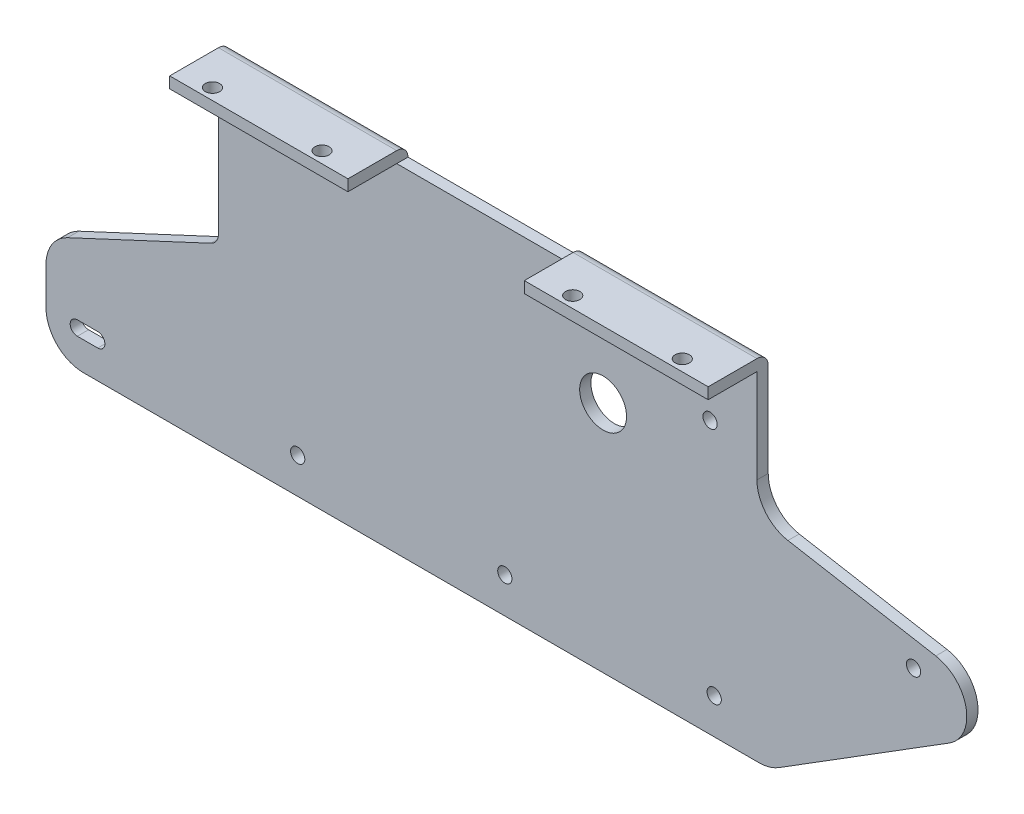
from build123d import *

# Parameters (mm, degrees)
BOSS_EXTRUDE1_DEPTH = 3
SKETCH2_R           = 1.9
SKETCH2_R_2         = 6.25
CUT_EXTRUDE1_DEPTH  = 4
BOSS_EXTRUDE3_DEPTH = 143.5
SKETCH6_W           = 47
SKETCH6_H           = 16
CUT_EXTRUDE4_DEPTH  = 3
SKETCH7_R           = 1.9
CUT_EXTRUDE5_DEPTH  = 94


with BuildPart() as part:
    # Sketch1 → Boss-Extrude1 (new body)
    with BuildSketch(Plane.XY):
        with BuildLine():
            Line((0, 0), (143.5, 0))
            Line((143.5, 0), (143.5, -25))
            ThreePointArc((143.5, -25), (145.839555569, -31.427876097), (151.763518223, -34.84807753))
            Line((151.763518223, -34.84807753), (191.155828344, -41.794004637))
            ThreePointArc((191.155828344, -41.794004637), (199.235618402, -49.733992213), (194.718539209, -60.122563128))
            Line((194.718539209, -60.122563128), (149.336384129, -88.480480962))
            ThreePointArc((149.336384129, -88.480480962), (146.793565045, -89.612616959), (144.037191487, -90))
            Line((144.037191487, -90), (-35.962808513, -90))
            ThreePointArc((-35.962808513, -90), (-43.033876325, -87.071067812), (-45.962808513, -80))
            Line((-45.962808513, -80), (-45.962808513, -70))
            ThreePointArc((-45.962808513, -70), (-44.396722971, -64.627003917), (-40.18899113, -60.93692213))
            Line((-40.18899113, -60.93692213), (-1.99069399, -43.124763645))
            ThreePointArc((-1.99069399, -43.124763645), (-0.539954223, -41.852499015), (0, -40))
            Line((0, -40), (0, 0))
        make_face()
    extrude(amount=BOSS_EXTRUDE1_DEPTH)

    # Sketch2 → Cut-Extrude1 (cut, through all)
    with BuildSketch(Plane.XY.offset(3)):
        with Locations((185.228339525, -47.568848131)):
            Circle(SKETCH2_R)
        with Locations((132.107823371, -80.5)):
            Circle(SKETCH2_R)
        with Locations((76.307823371, -80.5)):
            Circle(SKETCH2_R)
        with Locations((21.107823371, -80.5)):
            Circle(SKETCH2_R)
        with Locations((102.5, -27.75)):
            Circle(SKETCH2_R_2)
        with Locations((131.007823371, -17.5)):
            Circle(SKETCH2_R)
        with BuildLine():
            Line((-32.167176629, -82.4), (-37.617176629, -82.4))
            ThreePointArc((-37.617176629, -82.4), (-39.517176629, -80.5), (-37.617176629, -78.6))
            Line((-37.617176629, -78.6), (-32.167176629, -78.6))
            ThreePointArc((-32.167176629, -78.6), (-30.267176629, -80.5), (-32.167176629, -82.4))
        make_face()
    extrude(amount=-CUT_EXTRUDE1_DEPTH, mode=Mode.SUBTRACT)

    # Sketch3 → Boss-Extrude3 (add)
    with BuildSketch(Plane(origin=(143.5, 0, 0), x_dir=(0, 0, -1), z_dir=(1, 0, 0))):
        with BuildLine():
            Line((-3, 0), (0, 0))
            ThreePointArc((0, 0), (-0.878679656, 2.121320344), (-3, 3))
            Line((-3, 3), (-16, 3))
            Line((-16, 3), (-16, 0))
            Line((-16, 0), (-3, 0))
        make_face()
    extrude(amount=-BOSS_EXTRUDE3_DEPTH)

    # Sketch6 → Cut-Extrude4 (cut)
    with BuildSketch(Plane(origin=(0, 3, 0), x_dir=(1, 0, 0), z_dir=(0, 1, 0))):
        with Locations((71, -8)):
            Rectangle(SKETCH6_W, SKETCH6_H)
    extrude(amount=-CUT_EXTRUDE4_DEPTH, mode=Mode.SUBTRACT)

    # Sketch7 → Cut-Extrude5 (cut, through all)
    with BuildSketch(Plane(origin=(0, 3, 0), x_dir=(1, 0, 0), z_dir=(0, 1, 0))):
        with Locations((133.6, -13)):
            Circle(SKETCH7_R)
        with Locations((104.4, -13)):
            Circle(SKETCH7_R)
        with Locations((37.6, -13)):
            Circle(SKETCH7_R)
        with Locations((8.4, -13)):
            Circle(SKETCH7_R)
    extrude(amount=-CUT_EXTRUDE5_DEPTH, mode=Mode.SUBTRACT)


solid = part.part
